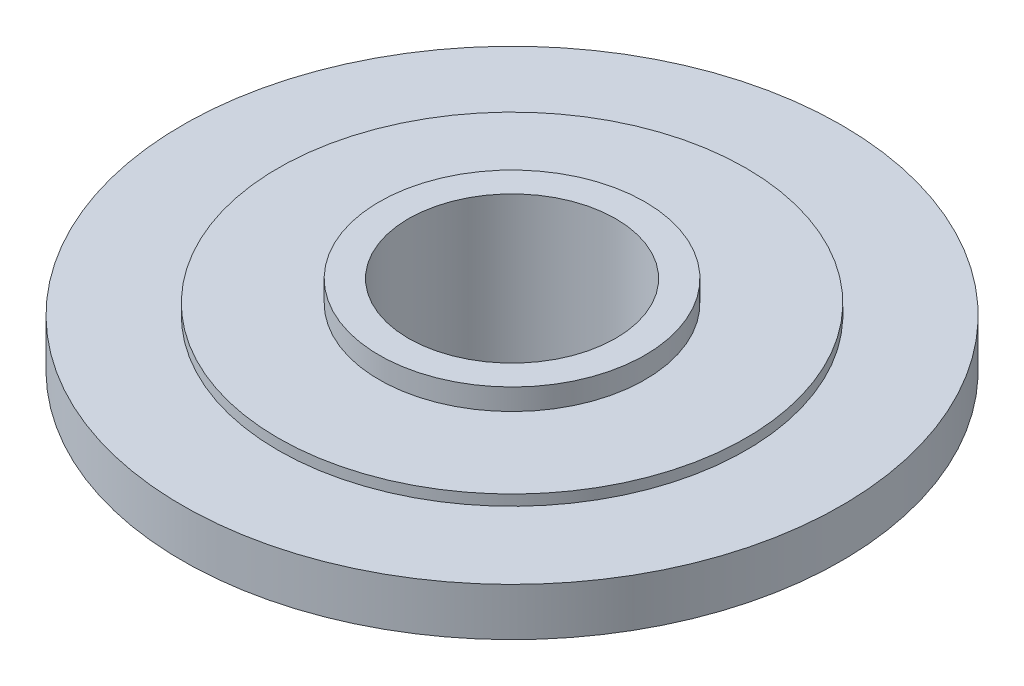
from build123d import *

# Parameters (mm, degrees)
SKETCH3_R          = 19.5
CUT_EXTRUDE1_DEPTH = 50


with BuildPart() as part:
    # Sketch2 → Revolve1 (revolve)
    with BuildSketch(Plane.XY):
        Polygon((0, 0), (26, 0), (26, 20), (30.5, 20), (30.5, 23), (62, 23), (62, 32), (44, 32), (44, 34), (25, 34), (25, 38), (0, 38), align=None)
    revolve(axis=Axis((0, 0, 0), (0, 1, 0)))

    # Sketch3 → Cut-Extrude1 (cut)
    with BuildSketch(Plane(origin=(0, 38, 0), x_dir=(1, 0, 0), z_dir=(0, 1, 0))):
        Circle(SKETCH3_R)
    extrude(amount=-CUT_EXTRUDE1_DEPTH, mode=Mode.SUBTRACT)


solid = part.part
